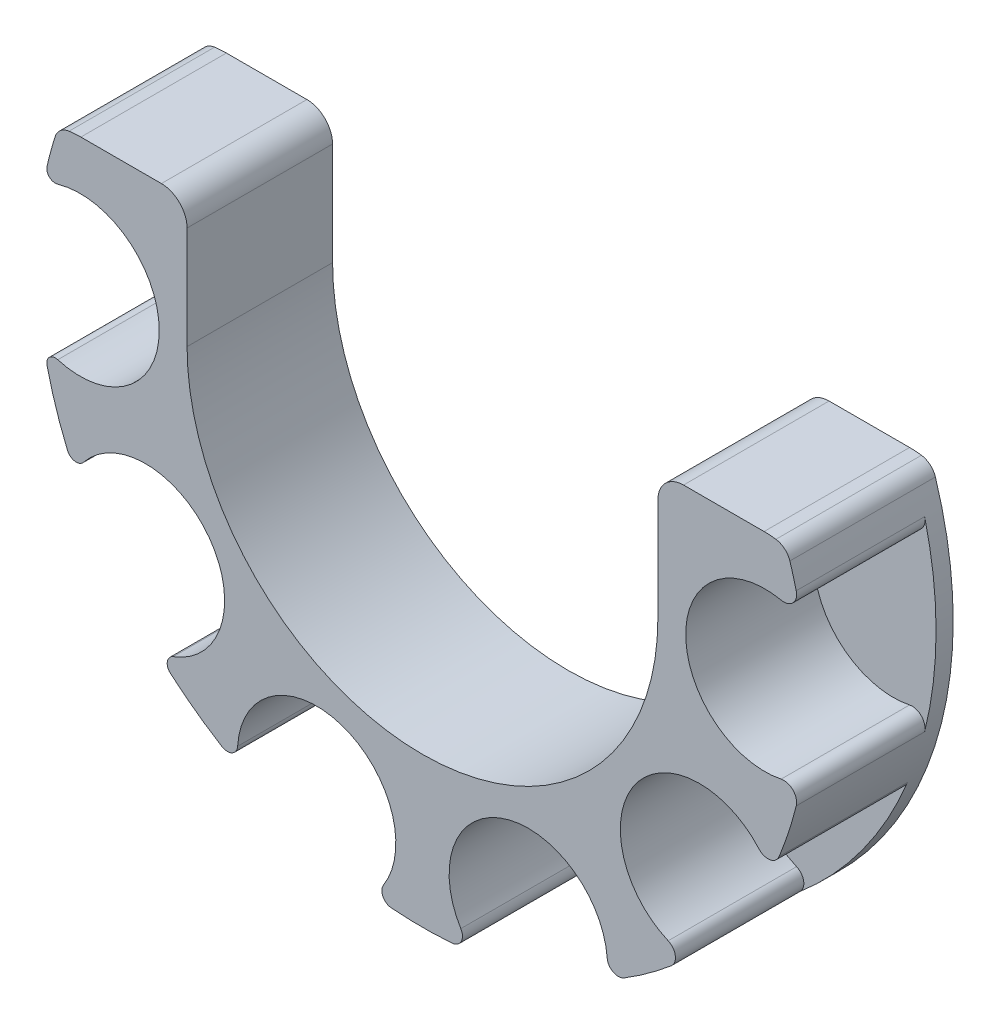
from build123d import *

# Parameters (mm, degrees)
EXTRUDE_1_DEPTH     = 17
CUT_EXTRUDE_1_DEPTH = 15
CUT_EXTRUDE_2_DEPTH = 15
CUT_EXTRUDE_3_DEPTH = 15
CUT_EXTRUDE_4_DEPTH = 15
CUT_EXTRUDE_5_DEPTH = 15
CUT_EXTRUDE_6_DEPTH = 15
CUT_EXTRUDE_7_DEPTH = 18
FILLET_1_R          = 2
FILLET_2_R          = 3


with BuildPart() as part:
    # 草图1 → 凸台-拉伸1 (new body)
    with BuildSketch(Plane(origin=(0, 0, 0), x_dir=(-1, 0, 0), z_dir=(0, 0, -1))):
        with BuildLine():
            Line((-10.093009514, -187.6), (-89.906992274, -187.6))
            ThreePointArc((-89.906992274, -187.6), (-91.240663452, -187.689332959), (-92.550506472, -187.955735762))
            ThreePointArc((-92.550506472, -187.955735762), (-50.000000894, -247.6), (-7.449495316, -187.955735762))
            ThreePointArc((-7.449495316, -187.955735762), (-8.759338336, -187.689332959), (-10.093009514, -187.6))
        make_face()
    extrude(amount=-EXTRUDE_1_DEPTH)

    # 草图2 → 切除-拉伸1 (cut)
    with BuildSketch(Plane.XY.offset(17)):
        with BuildLine():
            ThreePointArc((6.138583991, -212.658633467), (6.427726824, -211.707087742), (7.394913242, -211.47558552))
            ThreePointArc((7.394913242, -211.47558552), (19.250000894, -202.6), (7.394913242, -193.72441448))
            ThreePointArc((7.394913242, -193.72441448), (6.427726824, -193.492912258), (6.138583991, -192.541366533))
            ThreePointArc((6.138583991, -192.541366533), (5.000000894, -202.6), (6.138583991, -212.658633467))
        make_face()
    extrude(amount=-CUT_EXTRUDE_1_DEPTH, mode=Mode.SUBTRACT)

    # 草图3 → 切除-拉伸2 (cut)
    with BuildSketch(Plane.XY.offset(17)):
        with BuildLine():
            ThreePointArc((20.558692873, -236.632475402), (20.195546949, -235.606932185), (20.891610548, -234.770804613))
            ThreePointArc((20.891610548, -234.770804613), (25.122728317, -220.674396508), (10.408760237, -220.342398969))
            ThreePointArc((10.408760237, -220.342398969), (9.398460179, -220.746017161), (8.535328882, -220.083734582))
            ThreePointArc((8.535328882, -220.083734582), (13.594236147, -229.050336353), (20.558692873, -236.632475402))
        make_face()
    extrude(amount=-CUT_EXTRUDE_2_DEPTH, mode=Mode.SUBTRACT)

    # 草图4 → 切除-拉伸3 (cut)
    with BuildSketch(Plane.XY.offset(17)):
        with BuildLine():
            ThreePointArc((46.35614853, -247.452227815), (45.378748434, -246.7903036), (45.441184322, -245.611509143))
            ThreePointArc((45.441184322, -245.611509143), (40.497728317, -231.844987876), (28.406630222, -240.076646999))
            ThreePointArc((28.406630222, -240.076646999), (27.764263919, -241.067010643), (26.584461339, -241.028017219))
            ThreePointArc((26.584461339, -241.028017219), (36.094236147, -245.397543233), (46.35614853, -247.452227815))
        make_face()
    extrude(amount=-CUT_EXTRUDE_3_DEPTH, mode=Mode.SUBTRACT)

    # 草图5 → 切除-拉伸4 (cut)
    with BuildSketch(Plane.XY.offset(17)):
        with BuildLine():
            ThreePointArc((73.560141987, -240.939532492), (72.289088744, -240.990132521), (71.583355923, -239.931795197))
            ThreePointArc((71.583355923, -239.931795197), (59.502273471, -231.844987876), (54.481778538, -245.488434526))
            ThreePointArc((54.481778538, -245.488434526), (54.532903764, -246.759466752), (53.474858139, -247.465636818))
            ThreePointArc((53.474858139, -247.465636818), (63.905765641, -245.397543233), (73.560141987, -240.939532492))
        make_face()
    extrude(amount=-CUT_EXTRUDE_4_DEPTH, mode=Mode.SUBTRACT)

    # 草图6 → 切除-拉伸5 (cut)
    with BuildSketch(Plane.XY.offset(17)):
        with BuildLine():
            ThreePointArc((91.659654246, -219.613914382), (90.59547429, -220.46525304), (89.311552324, -220.008305698))
            ThreePointArc((89.311552324, -220.008305698), (74.877273471, -220.674396508), (78.704220933, -234.608044849))
            ThreePointArc((78.704220933, -234.608044849), (79.535557387, -235.687922708), (79.0547359, -236.963096102))
            ThreePointArc((79.0547359, -236.963096102), (86.405765641, -229.050336353), (91.659654246, -219.613914382))
        make_face()
    extrude(amount=-CUT_EXTRUDE_5_DEPTH, mode=Mode.SUBTRACT)

    # 草图7 → 切除-拉伸6 (cut)
    with BuildSketch(Plane.XY.offset(17)):
        with BuildLine():
            ThreePointArc((93.664063394, -191.716542553), (93.288877928, -193.119991574), (91.900418772, -193.547325705))
            ThreePointArc((91.900418772, -193.547325705), (80.750000894, -202.6), (91.900418772, -211.652674295))
            ThreePointArc((91.900418772, -211.652674295), (93.288877928, -212.080008426), (93.664063394, -213.483457447))
            ThreePointArc((93.664063394, -213.483457447), (95.000000894, -202.6), (93.664063394, -191.716542553))
        make_face()
    extrude(amount=-CUT_EXTRUDE_6_DEPTH, mode=Mode.SUBTRACT)

    # 草图8 → 切除-拉伸7 (cut, through all)
    with BuildSketch(Plane.XY.offset(17)):
        with BuildLine():
            Line((77.500000894, -187.6), (22.500000894, -187.6))
            Line((22.500000894, -187.6), (22.500000894, -202.6))
            ThreePointArc((22.500000894, -202.6), (50.000000894, -230.1), (77.500000894, -202.6))
            Line((77.500000894, -202.6), (77.500000894, -187.6))
        make_face()
    extrude(amount=-CUT_EXTRUDE_7_DEPTH, mode=Mode.SUBTRACT)

    # 圆角1
    fillet_1_edges = [part.edges().sort_by_distance(p)[0] for p in [
        (92.550506472, -187.955735762, 8.5),
        (7.449495316, -187.955735762, 8.5),
    ]]
    fillet(fillet_1_edges, radius=FILLET_1_R)

    # 圆角2
    fillet_2_edges = [part.edges().sort_by_distance(p)[0] for p in [
        (77.500000894, -187.6, 8.5),
        (22.500000894, -187.6, 8.5),
    ]]
    fillet(fillet_2_edges, radius=FILLET_2_R)


solid = part.part
